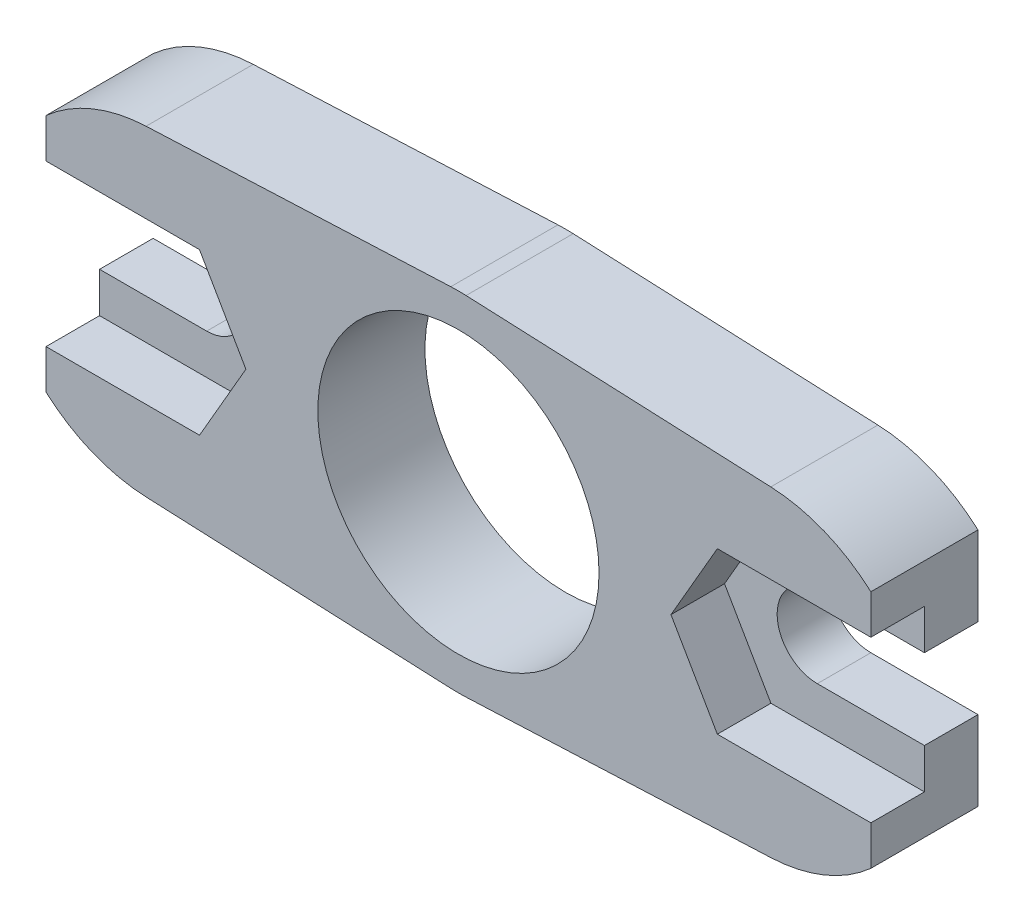
from build123d import *

# Parameters (mm, degrees)
EXTRUDE_1_DEPTH     = 6
SKETCH_2_R          = 5.25
CUT_EXTRUDE_1_DEPTH = 10
CUT_EXTRUDE_2_DEPTH = 2
SKETCH_4_W          = 2
SKETCH_4_H          = 14.987490134
CUT_EXTRUDE_3_DEPTH = 31.8


with BuildPart() as part:
    # Эскиз1 → Бобышка-Вытянуть1 (new body)
    with BuildSketch(Plane.XY):
        with BuildLine():
            Line((-136.336842105, -147.494226215), (-147.714912281, -147.993745067))
            ThreePointArc((-147.714912281, -147.993745067), (-148, -148), (-148.285087719, -147.993745067))
            Line((-148.285087719, -147.993745067), (-159.663157895, -147.494226215))
            ThreePointArc((-159.663157895, -147.494226215), (-161.66336442, -147.05672399), (-163.4, -145.972135955))
            Line((-163.4, -145.972135955), (-163.4, -143))
            Line((-163.4, -143), (-159.4, -143))
            ThreePointArc((-159.4, -143), (-157.9, -141.5), (-159.4, -140))
            Line((-159.4, -140), (-163.4, -140))
            Line((-163.4, -140), (-163.4, -137.027864045))
            ThreePointArc((-163.4, -137.027864045), (-161.66336442, -135.94327601), (-159.663157895, -135.505773785))
            Line((-159.663157895, -135.505773785), (-148.285087719, -135.006254933))
            ThreePointArc((-148.285087719, -135.006254933), (-148, -135), (-147.714912281, -135.006254933))
            Line((-147.714912281, -135.006254933), (-136.336842105, -135.505773785))
            ThreePointArc((-136.336842105, -135.505773785), (-134.33663558, -135.94327601), (-132.6, -137.027864045))
            Line((-132.6, -137.027864045), (-132.6, -140))
            Line((-132.6, -140), (-136.6, -140))
            ThreePointArc((-136.6, -140), (-138.1, -141.5), (-136.6, -143))
            Line((-136.6, -143), (-132.6, -143))
            Line((-132.6, -143), (-132.6, -145.972135955))
            ThreePointArc((-132.6, -145.972135955), (-134.33663558, -147.05672399), (-136.336842105, -147.494226215))
        make_face()
    extrude(amount=EXTRUDE_1_DEPTH)

    # Эскиз2 → Вырез-Вытянуть1 (cut)
    with BuildSketch(Plane.XY.offset(6)):
        with Locations((-148, -141.5)):
            Circle(SKETCH_2_R)
    extrude(amount=-CUT_EXTRUDE_1_DEPTH, mode=Mode.SUBTRACT)

    # Эскиз3 → Вырез-Вытянуть2 (cut)
    with BuildSketch(Plane.XY.offset(6)):
        Polygon((-132.6, -138.5), (-134.867949192, -138.5), (-134.001923789, -140), (-132.6, -140), align=None)
        with BuildLine():
            Line((-134.001923789, -140), (-134.867949192, -138.5))
            Line((-134.867949192, -138.5), (-138.332050808, -138.5))
            Line((-138.332050808, -138.5), (-140.064101615, -141.5))
            Line((-140.064101615, -141.5), (-138.332050808, -144.5))
            Line((-138.332050808, -144.5), (-134.867949192, -144.5))
            Line((-134.867949192, -144.5), (-134.001923789, -143))
            Line((-134.001923789, -143), (-136.6, -143))
            ThreePointArc((-136.6, -143), (-138.1, -141.5), (-136.6, -140))
            Line((-136.6, -140), (-134.001923789, -140))
        make_face()
        Polygon((-132.6, -143), (-134.001923789, -143), (-134.867949192, -144.5), (-132.6, -144.5), align=None)
        with BuildLine():
            Line((-157.667949192, -138.5), (-161.132050808, -138.5))
            Line((-161.132050808, -138.5), (-161.998076211, -140))
            Line((-161.998076211, -140), (-159.4, -140))
            ThreePointArc((-159.4, -140), (-157.9, -141.5), (-159.4, -143))
            Line((-159.4, -143), (-161.998076211, -143))
            Line((-161.998076211, -143), (-161.132050808, -144.5))
            Line((-161.132050808, -144.5), (-157.667949192, -144.5))
            Line((-157.667949192, -144.5), (-155.935898385, -141.5))
            Line((-155.935898385, -141.5), (-157.667949192, -138.5))
        make_face()
        Polygon((-161.998076211, -140), (-161.132050808, -138.5), (-163.4, -138.5), (-163.4, -140), align=None)
        Polygon((-161.998076211, -143), (-163.4, -143), (-163.4, -144.5), (-161.132050808, -144.5), align=None)
    extrude(amount=-CUT_EXTRUDE_2_DEPTH, mode=Mode.SUBTRACT)

    # Эскиз4 → Вырез-Вытянуть3 (cut, through all)
    with BuildSketch(Plane(origin=(-132.6, 0, 0), x_dir=(0, 0, -1), z_dir=(1, 0, 0))):
        with Locations((-1, -141.5)):
            Rectangle(SKETCH_4_W, SKETCH_4_H)
    extrude(amount=-CUT_EXTRUDE_3_DEPTH, mode=Mode.SUBTRACT)


solid = part.part
